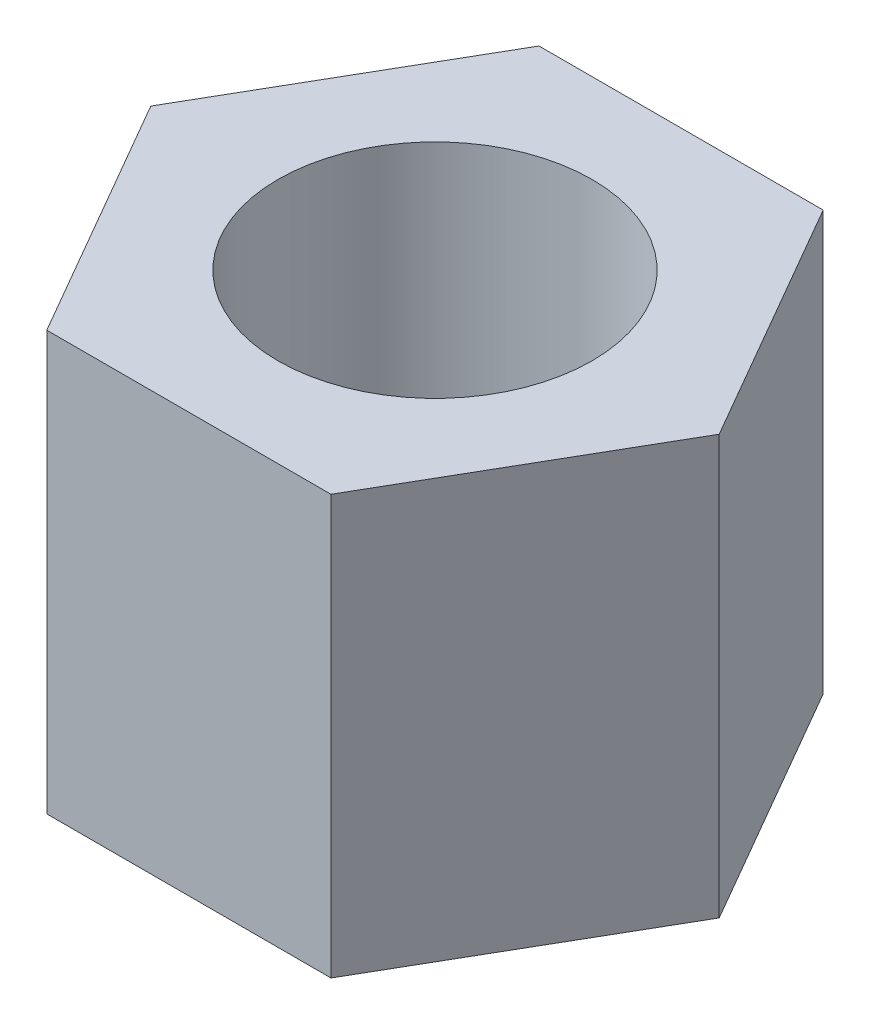
from build123d import *

# Parameters (mm, degrees)
EXTRUDE_1_DEPTH     = 4
SKETCH_2_R          = 1.5
CUT_EXTRUDE_1_DEPTH = 5


with BuildPart() as part:
    # 草图1 → 凸台-拉伸1 (new body)
    with BuildSketch(Plane(origin=(0, 0, 0), x_dir=(1, 0, 0), z_dir=(0, 1, 0))):
        Polygon((2.713546265, 0), (1.356773133, 2.35), (-1.356773133, 2.35), (-2.713546265, 0), (-1.356773133, -2.35), (1.356773133, -2.35), align=None)
    extrude(amount=EXTRUDE_1_DEPTH)

    # 草图2 → 切除-拉伸1 (cut, through all)
    with BuildSketch(Plane(origin=(0, 4, 0), x_dir=(1, 0, 0), z_dir=(0, 1, 0))):
        Circle(SKETCH_2_R)
    extrude(amount=-CUT_EXTRUDE_1_DEPTH, mode=Mode.SUBTRACT)


solid = part.part
